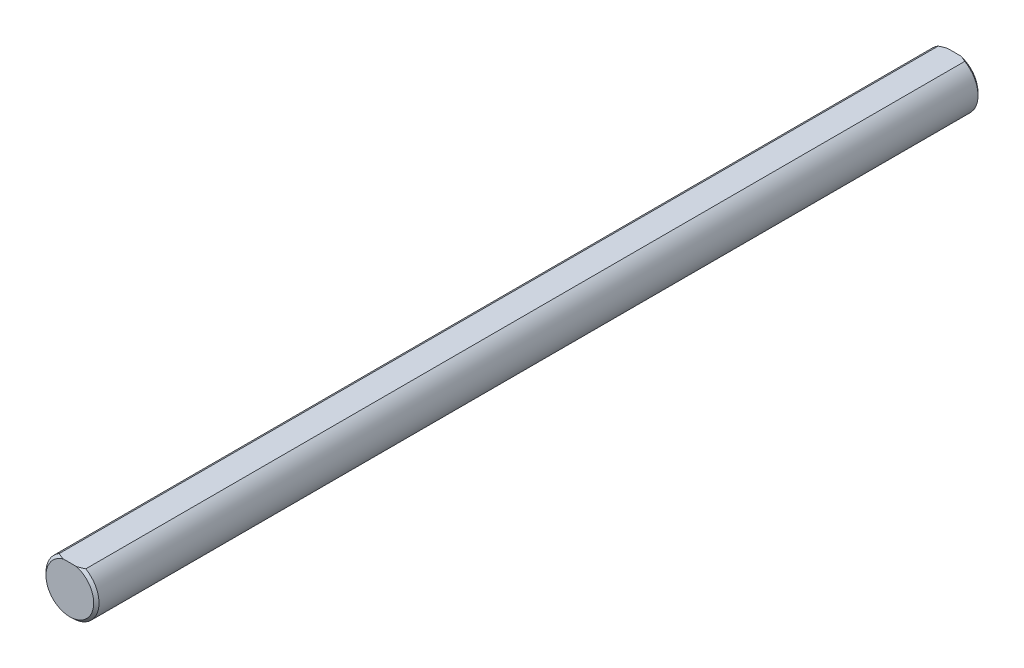
from build123d import *

# Parameters (mm, degrees)
SKETCH3_R                = 6
BOSS_EXTRUDE2_DEPTH      = 100
BOSS_EXTRUDE2_DEPTH_BACK = 100
CUT_EXTRUDE5_DEPTH       = 101
CUT_EXTRUDE5_DEPTH_BACK  = 101
CHAMFER1_SIZE            = 0.6


with BuildPart() as part:
    # Sketch3 → Boss-Extrude2 (new body, two sides)
    with BuildSketch(Plane.XY) as boss_extrude2_sk:
        Circle(SKETCH3_R)
    extrude(amount=BOSS_EXTRUDE2_DEPTH)
    extrude(boss_extrude2_sk.sketch, amount=-BOSS_EXTRUDE2_DEPTH_BACK)

    # Sketch10 → Cut-Extrude5 (cut, two sides)
    with BuildSketch(Plane.XY) as cut_extrude5_sk:
        with BuildLine():
            Line((-3, 5.196152423), (3, 5.196152423))
            ThreePointArc((3, 5.196152423), (0, 6), (-3, 5.196152423))
        make_face()
    extrude(amount=CUT_EXTRUDE5_DEPTH, mode=Mode.SUBTRACT)
    extrude(cut_extrude5_sk.sketch, amount=-CUT_EXTRUDE5_DEPTH_BACK, mode=Mode.SUBTRACT)

    # Chamfer1
    chamfer1_edges = [part.edges().sort_by_distance(p)[0] for p in [
        (0, -6, -100),
        (0, -6, 100),
    ]]
    chamfer(chamfer1_edges, length=CHAMFER1_SIZE)


solid = part.part
